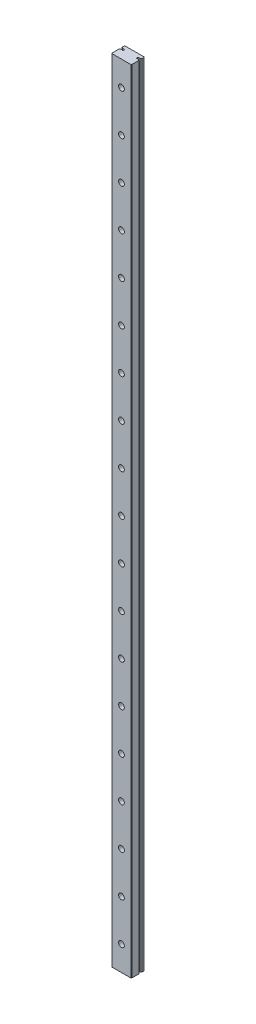
from build123d import *

# Parameters (mm, degrees)
SKETCH1_W                                        = 12
SKETCH1_H                                        = 480
BOSS_EXTRUDE1_DEPTH                              = 8
CUT_EXTRUDE1_DEPTH                               = 481
CUT_EXTRUDE2_DEPTH                               = 481
CUT_EXTRUDE3_DEPTH                               = 481
CUT_EXTRUDE4_DEPTH                               = 481
CBORE_FOR_M3_HEX_HEAD_MACHINE_SCREW1_D           = 3.5
CBORE_FOR_M3_HEX_HEAD_MACHINE_SCREW1_DEPTH       = 8
CBORE_FOR_M3_HEX_HEAD_MACHINE_SCREW1_CBORE_D     = 6
CBORE_FOR_M3_HEX_HEAD_MACHINE_SCREW1_CBORE_DEPTH = 4.5
CHAMFER1_SIZE                                    = 0.5
CHAMFER2_SIZE                                    = 0.2977


with BuildPart() as part:
    # Sketch1 → Boss-Extrude1 (new body)
    with BuildSketch(Plane(origin=(0, 0, -4), x_dir=(-1, 0, 0), z_dir=(0, 0, -1))):
        with Locations((0.030537514, 240)):
            Rectangle(SKETCH1_W, SKETCH1_H)
    extrude(amount=-BOSS_EXTRUDE1_DEPTH)

    # Sketch2 → Cut-Extrude1 (cut, through all)
    with BuildSketch(Plane(origin=(0, 480, 0), x_dir=(-1, 0, 0), z_dir=(0, 1, 0))):
        with BuildLine():
            Line((6.030537514, -2.4577), (6.030537514, -1.0033))
            Line((6.030537514, -1.0033), (4.048874358, -1.0033))
            Line((4.048874358, -1.0033), (4.048874358, -1.9939))
            Line((4.048874358, -1.9939), (5.420474358, -1.9939))
            ThreePointArc((5.420474358, -1.9939), (5.678839101, -2.287183606), (6.030537514, -2.4577))
        make_face()
    extrude(amount=-CUT_EXTRUDE1_DEPTH, mode=Mode.SUBTRACT)

    # Sketch3 → Cut-Extrude2 (cut, through all)
    with BuildSketch(Plane(origin=(0, 480, 0), x_dir=(-1, 0, 0), z_dir=(0, 1, 0))):
        with BuildLine():
            Line((-5.969462486, -1.0033), (-5.969462486, -2.4577))
            ThreePointArc((-5.969462486, -2.4577), (-5.617764074, -2.287183606), (-5.35939933, -1.9939))
            Line((-5.35939933, -1.9939), (-3.98779933, -1.9939))
            Line((-3.98779933, -1.9939), (-3.98779933, -1.0033))
            Line((-3.98779933, -1.0033), (-5.969462486, -1.0033))
        make_face()
    extrude(amount=-CUT_EXTRUDE2_DEPTH, mode=Mode.SUBTRACT)

    # Sketch4 → Cut-Extrude3 (cut, through all)
    with BuildSketch(Plane(origin=(0, 480, 0), x_dir=(-1, 0, 0), z_dir=(0, 1, 0))):
        with BuildLine():
            Line((-5.969462486, -1.0033), (-5.35939933, -1.0033))
            ThreePointArc((-5.35939933, -1.0033), (-5.617764074, -0.710016394), (-5.969462486, -0.5395))
            Line((-5.969462486, -0.5395), (-5.969462486, -1.0033))
        make_face()
    extrude(amount=-CUT_EXTRUDE3_DEPTH, mode=Mode.SUBTRACT)

    # Sketch5 → Cut-Extrude4 (cut, through all)
    with BuildSketch(Plane(origin=(0, 480, 0), x_dir=(-1, 0, 0), z_dir=(0, 1, 0))):
        with BuildLine():
            Line((6.030537514, -1.0033), (6.030537514, -0.5395))
            ThreePointArc((6.030537514, -0.5395), (5.678839101, -0.710016394), (5.420474358, -1.0033))
            Line((5.420474358, -1.0033), (6.030537514, -1.0033))
        make_face()
    extrude(amount=-CUT_EXTRUDE4_DEPTH, mode=Mode.SUBTRACT)

    # CBORE for M3 Hex Head Machine Screw1
    with Locations(Plane(origin=(0, 0, -4), x_dir=(-1, 0, 0), z_dir=(0, 0, -1))):
        with Locations((0, 465), (0, 440), (0, 415), (0, 390), (0, 365), (0, 340), (0, 315), (0, 290), (0, 265), (0, 240), (0, 215), (0, 190), (0, 165), (0, 140), (0, 115), (0, 90), (0, 65), (0, 40), (0, 15)):
            CounterBoreHole(CBORE_FOR_M3_HEX_HEAD_MACHINE_SCREW1_D / 2, CBORE_FOR_M3_HEX_HEAD_MACHINE_SCREW1_CBORE_D / 2, CBORE_FOR_M3_HEX_HEAD_MACHINE_SCREW1_CBORE_DEPTH, depth=CBORE_FOR_M3_HEX_HEAD_MACHINE_SCREW1_DEPTH)

    # Chamfer1
    chamfer1_edges = [part.edges().sort_by_distance(p)[0] for p in [
        (3, 65, -4),
        (3, 90, -4),
        (3, 115, -4),
        (3, 140, -4),
        (3, 165, -4),
        (3, 190, -4),
        (3, 215, -4),
        (3, 240, -4),
        (3, 265, -4),
        (3, 290, -4),
        (3, 315, -4),
        (3, 340, -4),
        (3, 365, -4),
        (3, 390, -4),
        (3, 415, -4),
        (3, 440, -4),
        (3, 465, -4),
        (3, 15, -4),
        (3, 40, -4),
    ]]
    chamfer(chamfer1_edges, length=CHAMFER1_SIZE)

    # Chamfer2
    chamfer2_edges = [part.edges().sort_by_distance(p)[0] for p in [
        (-6.030537514, 240, 4),
        (5.969462486, 240, 4),
        (-6.030537514, 240, -4),
        (5.969462486, 240, -4),
    ]]
    chamfer(chamfer2_edges, length=CHAMFER2_SIZE)


solid = part.part
